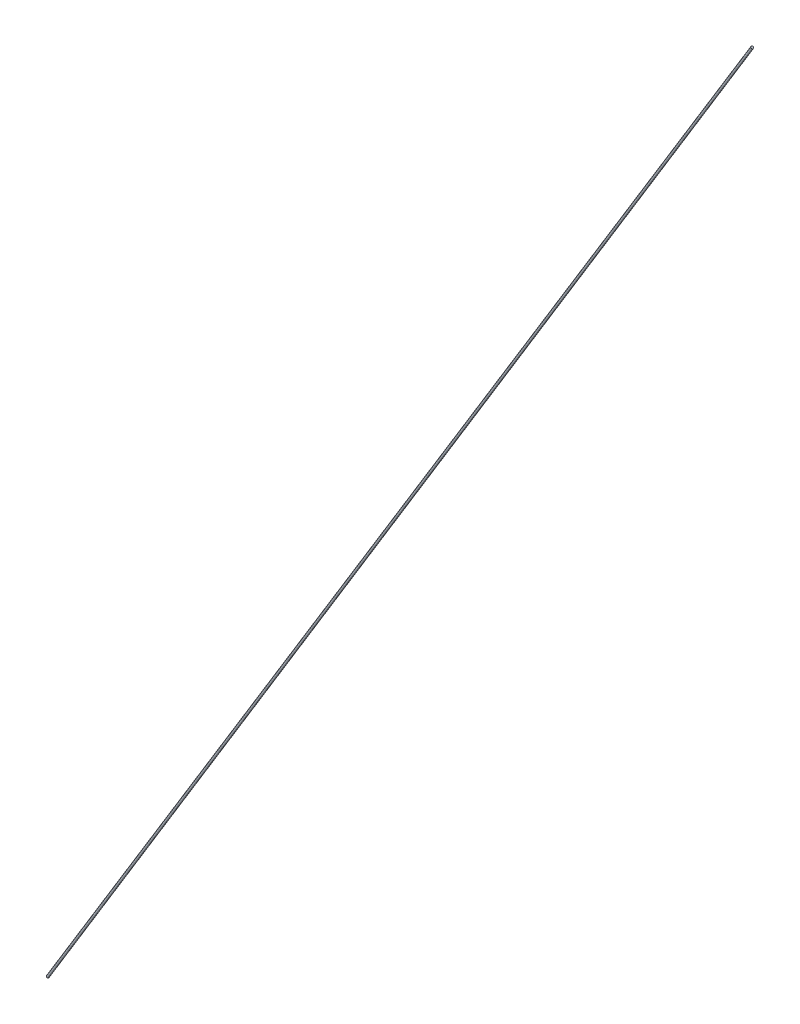
from build123d import *

# Parameters (mm, degrees)
SWEEP_1_PROFILE_R = 0.5


with BuildPart() as part:
    # 扫描1: sweep along a path in 草图2
    with BuildLine(Plane.XY) as sweep_1_path:
        Line((307.5, 505), (0, 0))
    # 扫描1 profile (on start of the path) → 扫描1 (sweep)
    with BuildSketch(Plane(origin=(307.5, 505, 0), x_dir=(-0.854116895, 0.52008108, 0), z_dir=(-0.52008108, -0.854116895, 0))):
        Circle(SWEEP_1_PROFILE_R)
    sweep(path=sweep_1_path.line)


solid = part.part
